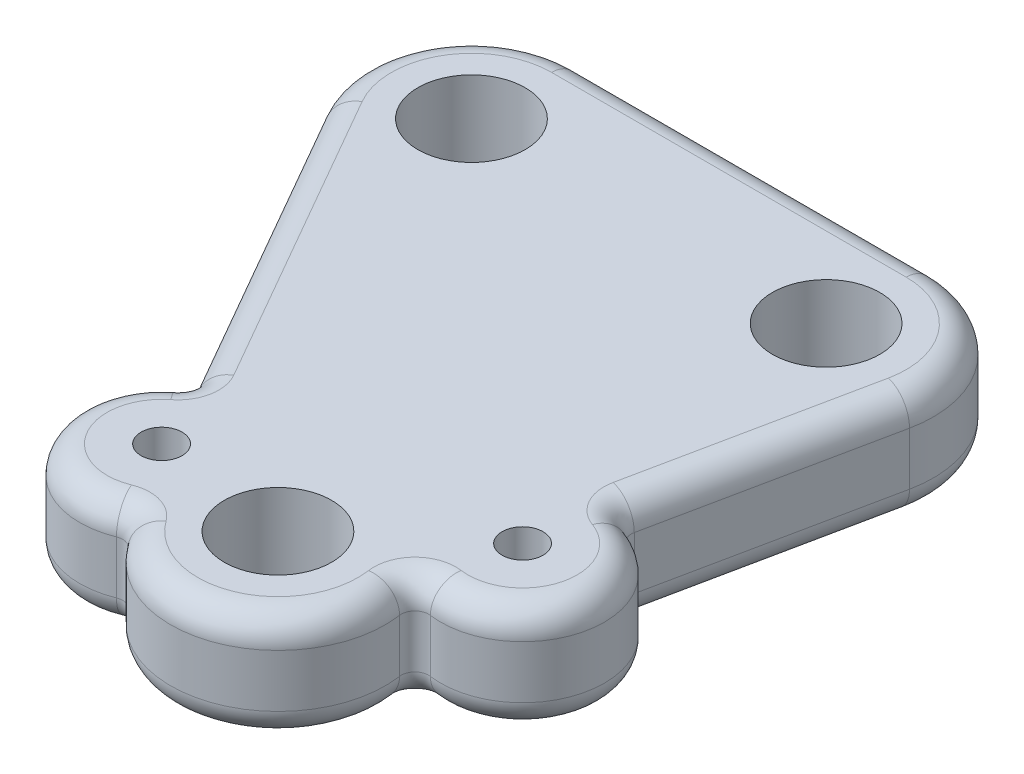
from build123d import *

# Parameters (mm, degrees)
SKETCH1_R           = 5
SKETCH1_R_2         = 1.905
BOSS_EXTRUDE1_DEPTH = 10
FILLET2_R           = 1.27
FILLET1_R           = 2.54
SCALE1_SCALE        = 0.66


with BuildPart() as part:
    # Sketch1 → Boss-Extrude1 (new body)
    with BuildSketch(Plane(origin=(0, 0, 0), x_dir=(1, 0, 0), z_dir=(0, 1, 0))):
        with BuildLine():
            Line((-41.693402896, -4.977156036), (-25.014953019, -34.04172914))
            ThreePointArc((-25.014953019, -34.04172914), (-27.831493127, -44.443455046), (-17.42976722, -47.259995153))
            ThreePointArc((-17.42976722, -47.259995153), (-4.558655696, -51.359140251), (0.652959758, -38.896894596))
            ThreePointArc((0.652959758, -38.896894596), (10.887641345, -34.13704865), (5.156505389, -24.412907491))
            Line((5.156505389, -24.412907491), (9.792227679, -2.027875017))
            ThreePointArc((9.792227679, -2.027875017), (7.754958097, 6.313527137), (0, 10))
            Line((0, 10), (-33.02, 10))
            ThreePointArc((-33.02, 10), (-41.673657041, 5.011408966), (-41.693402896, -4.977156036))
        make_face()
        with Locations((-33.02, 0)):
            Circle(SKETCH1_R, mode=Mode.SUBTRACT)
        Circle(SKETCH1_R, mode=Mode.SUBTRACT)
        with Locations((-8.756364325, -42.282839117)):
            Circle(SKETCH1_R, mode=Mode.SUBTRACT)
        with Locations((-21.22236012, -40.650862147)):
            Circle(SKETCH1_R_2, mode=Mode.SUBTRACT)
        with Locations((3.611264626, -31.874584982)):
            Circle(SKETCH1_R_2, mode=Mode.SUBTRACT)
    extrude(amount=BOSS_EXTRUDE1_DEPTH)

    # Fillet2
    fillet2_edges = [part.edges().sort_by_distance(p)[0] for p in [
        (5.156505389, 5, 24.412907491),
        (0.652959758, 5, 38.896894596),
        (-17.42976722, 5, 47.259995153),
        (-25.014953019, 5, 34.04172914),
    ]]
    fillet(fillet2_edges, radius=FILLET2_R)

    # Fillet1
    fillet1_edges = [part.edges().sort_by_distance(p)[0] for p in [
        (-33.647536039, 0, 18.998224371),
        (-41.673657041, 0, -5.011408966),
        (7.754958097, 10, -6.313527137),
        (-16.51, 10, -10),
        (-41.673657041, 10, -5.011408966),
        (7.593891323, 0, 12.643228492),
        (7.593891323, 10, 12.643228492),
        (11.008943171, 0, 33.70181024),
        (11.008943171, 10, 33.70181024),
        (-5.004925911, 0, 51.552505229),
        (-5.004925911, 10, 51.552505229),
        (-27.817933745, 0, 44.466986955),
        (-27.817933745, 10, 44.466986955),
        (5.530485293, 0, 24.135575816),
        (5.530485293, 10, 24.135575816),
        (1.498671614, 0, 39.786171251),
        (1.498671614, 10, 39.786171251),
        (-17.535076824, 0, 47.670329533),
        (-17.535076824, 10, 47.670329533),
        (-25.456713049, 0, 33.89468526),
        (-25.456713049, 10, 33.89468526),
        (-33.647536039, 10, 18.998224371),
        (-16.51, 0, -10),
        (7.754958097, 0, -6.313527137),
    ]]
    fillet(fillet1_edges, radius=FILLET1_R)


with BuildPart() as part_1:
    # Scale1: scaled about (-13.667161436, 5, 16.92089014)
    add(part.part.scale(SCALE1_SCALE).moved(Location((-4.646834888, 1.7, 5.753102648))))


solid = part_1.part
